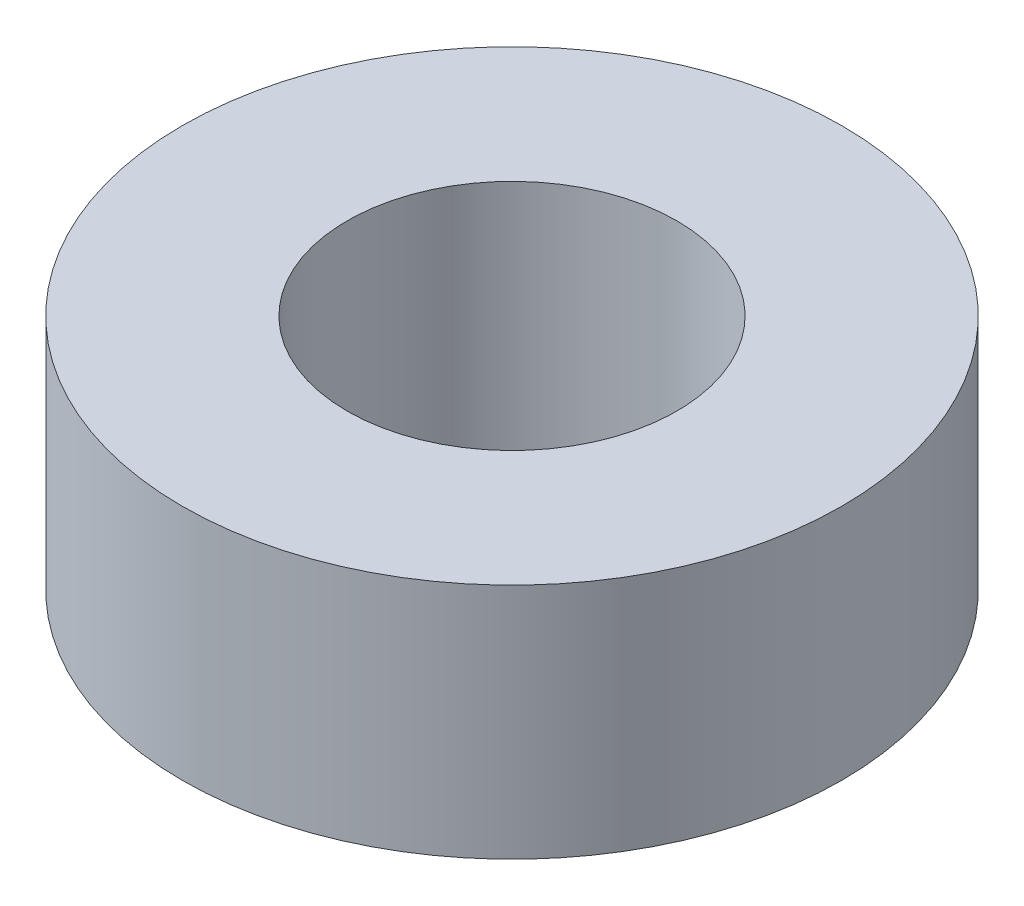
from build123d import *

# Parameters (mm, degrees)
SKETCH1_R           = 12.5
SKETCH1_R_2         = 6.25
BOSS_EXTRUDE1_DEPTH = 9


with BuildPart() as part:
    # Sketch1 → Boss-Extrude1 (new body)
    with BuildSketch(Plane(origin=(0, 0, 0), x_dir=(1, 0, 0), z_dir=(0, 1, 0))):
        Circle(SKETCH1_R)
        Circle(SKETCH1_R_2, mode=Mode.SUBTRACT)
    extrude(amount=BOSS_EXTRUDE1_DEPTH)


solid = part.part
